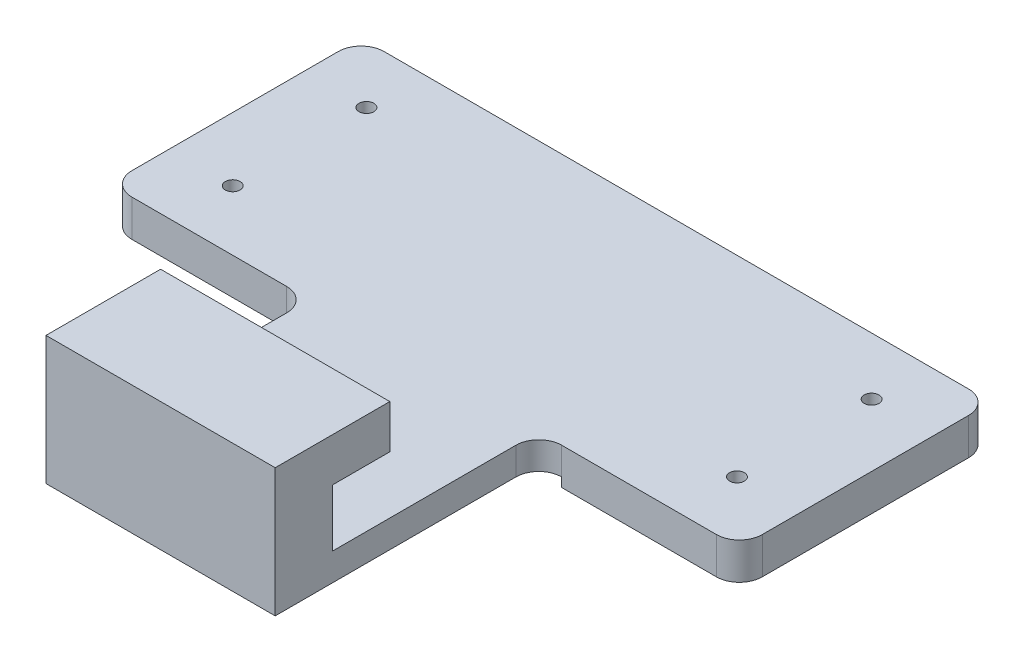
from build123d import *

# Parameters (mm, degrees)
SKETCH1_W                = 69.85
SKETCH1_H                = 57.15
BOSS_EXTRUDE1_DEPTH      = 15.24
SKETCH2_W                = 50.8
SKETCH2_H                = 6.35
CUT_EXTRUDE1_DEPTH       = 69.85
SKETCH3_W                = 44.45
SKETCH3_H                = 4.826
CUT_EXTRUDE2_DEPTH       = 50.8
SKETCH5_W                = 61.722
SKETCH5_H                = 20.0000108
SKETCH5_R                = 0.81915
CUT_EXTRUDE3_DEPTH       = 1.016
SKETCH5_3_R              = 0.81915
CUT_EXTRUDE4_DEPTH       = 16.24
SKETCH7_W                = 69.85
SKETCH7_H                = 6.096
BOSS_EXTRUDE2_DEPTH      = 6.35
SKETCH8_W                = 6.35
SKETCH8_H                = 1.27
CUT_EXTRUDE9_DEPTH       = 1
CUT_EXTRUDE9_DEPTH_BACK  = 70.85
SKETCH17_W               = 22.225
SKETCH17_H               = 4.826
CUT_EXTRUDE13_DEPTH      = 6.35
SKETCH18_W               = 22.225
SKETCH18_H               = 29.21
CUT_EXTRUDE14_DEPTH      = 1
CUT_EXTRUDE14_DEPTH_BACK = 16.24
FILLET1_R                = 2.54
SKETCH19_W               = 30.48
SKETCH19_H               = 33.3399892
CUT_EXTRUDE16_DEPTH      = 1.016


with BuildPart() as part:
    # Sketch1 → Boss-Extrude1 (new body)
    with BuildSketch(Plane(origin=(0, 0, 0), x_dir=(1, 0, 0), z_dir=(0, 1, 0))):
        Rectangle(SKETCH1_W, SKETCH1_H)
    extrude(amount=BOSS_EXTRUDE1_DEPTH)

    # Sketch2 → Cut-Extrude1 (cut)
    with BuildSketch(Plane.ZY.offset(34.925)):
        with Locations((-3.175, 7.239)):
            Rectangle(SKETCH2_W, SKETCH2_H)
    extrude(amount=-CUT_EXTRUDE1_DEPTH, mode=Mode.SUBTRACT)

    # Sketch3 → Cut-Extrude2 (cut)
    with BuildSketch(Plane.ZY.offset(34.925)):
        with Locations((-6.35, 12.827)):
            Rectangle(SKETCH3_W, SKETCH3_H)
    cut_extrude2 = extrude(amount=-CUT_EXTRUDE2_DEPTH, mode=Mode.SUBTRACT)

    # Mirror1: Cut-Extrude2 across plane
    add(cut_extrude2.mirror(Plane(origin=(0, 0, 0), x_dir=(0, 0, 1), z_dir=(1, 0, 0))), mode=Mode.SUBTRACT)

    # Sketch5 → Cut-Extrude3 (cut)
    with BuildSketch(Plane.XZ):
        with Locations((0, -14.7649946)):
            Rectangle(SKETCH5_W, SKETCH5_H)
        with Locations((-27.8892, -7.3049892)):
            Circle(SKETCH5_R, mode=Mode.SUBTRACT)
        with Locations((27.9908, -7.3049892)):
            Circle(SKETCH5_R, mode=Mode.SUBTRACT)
    extrude(amount=-CUT_EXTRUDE3_DEPTH, mode=Mode.SUBTRACT)

    # Sketch5_3 → Cut-Extrude4 (cut, through all)
    with BuildSketch(Plane.XZ):
        with Locations((-27.9908, -22.225)):
            Circle(SKETCH5_3_R)
        with Locations((27.9908, -22.225)):
            Circle(SKETCH5_3_R)
        with Locations((-27.8892, -7.3049892)):
            Circle(SKETCH5_3_R)
        with Locations((27.9908, -7.3049892)):
            Circle(SKETCH5_3_R)
    extrude(amount=-CUT_EXTRUDE4_DEPTH, mode=Mode.SUBTRACT)

    # Sketch7 → Boss-Extrude2 (add)
    with BuildSketch(Plane(origin=(0, 0, 22.225), x_dir=(-1, 0, 0), z_dir=(0, 0, -1))):
        with Locations((0, 12.192)):
            Rectangle(SKETCH7_W, SKETCH7_H)
    extrude(amount=BOSS_EXTRUDE2_DEPTH)

    # Sketch8 → Cut-Extrude9 (cut, two sides)
    with BuildSketch(Plane.ZY.offset(34.925)) as cut_extrude9_sk:
        with Locations((19.05, 9.779)):
            Rectangle(SKETCH8_W, SKETCH8_H)
    extrude(amount=CUT_EXTRUDE9_DEPTH, mode=Mode.SUBTRACT)
    extrude(cut_extrude9_sk.sketch, amount=-CUT_EXTRUDE9_DEPTH_BACK, mode=Mode.SUBTRACT)

    # Sketch17 → Cut-Extrude13 (cut)
    with BuildSketch(Plane(origin=(0, 0, 15.875), x_dir=(-1, 0, 0), z_dir=(0, 0, -1))):
        with Locations((-23.8125, 12.827)):
            Rectangle(SKETCH17_W, SKETCH17_H)
        with Locations((23.8125, 12.827)):
            Rectangle(SKETCH17_W, SKETCH17_H)
    extrude(amount=-CUT_EXTRUDE13_DEPTH, mode=Mode.SUBTRACT)

    # Sketch18 → Cut-Extrude14 (cut, two sides)
    with BuildSketch(Plane(origin=(0, 15.24, 0), x_dir=(1, 0, 0), z_dir=(0, 1, 0))) as cut_extrude14_sk:
        with Locations((-23.8125, -13.97)):
            Rectangle(SKETCH18_W, SKETCH18_H)
        with Locations((23.8125, -13.97)):
            Rectangle(SKETCH18_W, SKETCH18_H)
    extrude(amount=CUT_EXTRUDE14_DEPTH, mode=Mode.SUBTRACT)
    extrude(cut_extrude14_sk.sketch, amount=-CUT_EXTRUDE14_DEPTH_BACK, mode=Mode.SUBTRACT)

    # Fillet1
    fillet1_edges = [part.edges().sort_by_distance(p)[0] for p in [
        (-34.925, 2.032, -28.575),
        (34.925, 2.032, -28.575),
        (-34.925, 2.032, -0.635),
        (-12.7, 2.032, -0.635),
        (34.925, 2.032, -0.635),
        (12.7, 2.032, -0.635),
    ]]
    fillet(fillet1_edges, radius=FILLET1_R)

    # Sketch19 → Cut-Extrude16 (cut)
    with BuildSketch(Plane.XZ):
        with Locations((0, 11.9050054)):
            Rectangle(SKETCH19_W, SKETCH19_H)
    extrude(amount=-CUT_EXTRUDE16_DEPTH, mode=Mode.SUBTRACT)


solid = part.part
